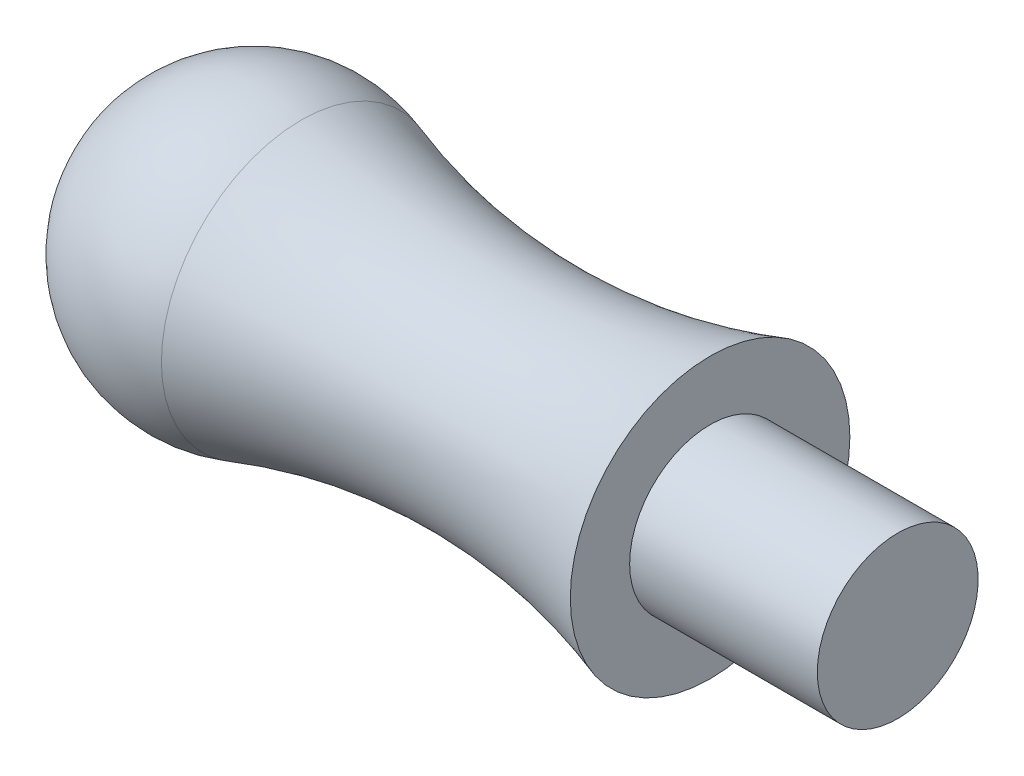
from build123d import *


with BuildPart() as part:
    # Sketch1 → Revolve1 (revolve)
    with BuildSketch(Plane.XY):
        with BuildLine():
            Line((0, 0), (24, 0))
            Line((24, 0), (24, 3))
            Line((24, 3), (17, 3))
            Line((17, 3), (17, 5.21494699))
            ThreePointArc((17, 5.21494699), (9.373831776, 3.971079311), (1.747663551, 5.21494699))
            ThreePointArc((1.747663551, 5.21494699), (-3.212308396, 4.464423229), (-5.5, 0))
            Line((-5.5, 0), (0, 0))
        make_face()
    revolve(axis=Axis((0, 0, 0), (1, 0, 0)))


solid = part.part
